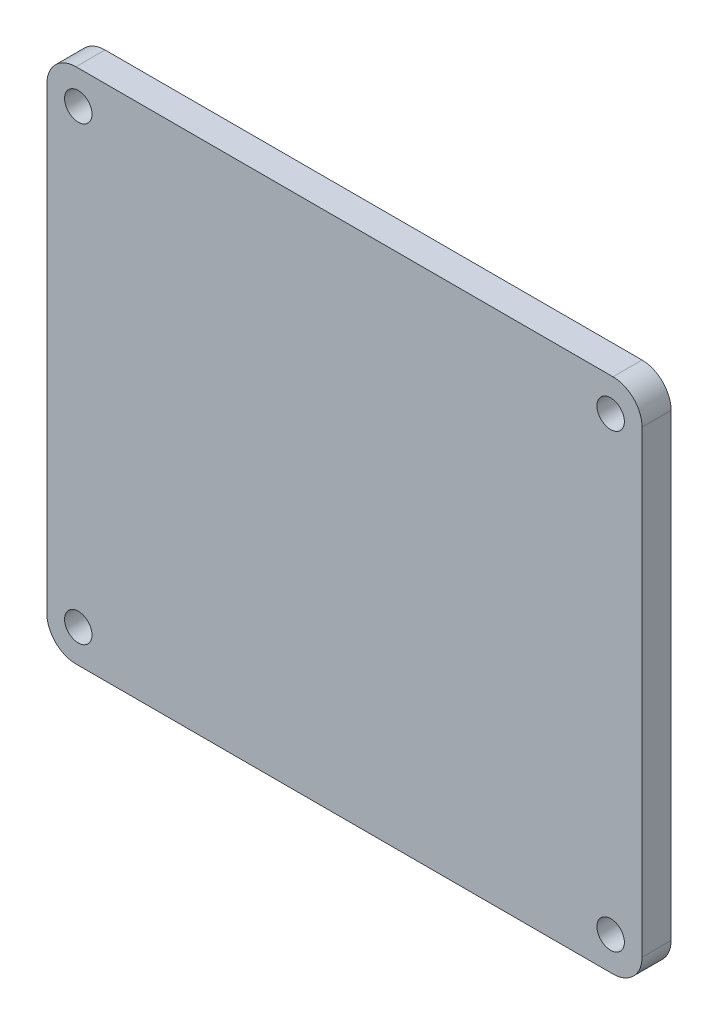
from build123d import *

# Parameters (mm, degrees)
SKETCH2_W                 = 65.024
SKETCH2_H                 = 56.515
BOSS_EXTRUDE1_DEPTH       = 3.175
F_3_0MM_DOWEL_HOLE1_D     = 3
F_3_0MM_DOWEL_HOLE1_DEPTH = 3.175
FILLET1_R                 = 3.175


with BuildPart() as part:
    # Sketch2 → Boss-Extrude1 (new body)
    with BuildSketch(Plane.XY.offset(50.8)):
        with Locations((0, 48.5775)):
            Rectangle(SKETCH2_W, SKETCH2_H)
    extrude(amount=-BOSS_EXTRUDE1_DEPTH)

    # Ø3.0mm Dowel Hole1
    with Locations(Plane.XY.offset(50.8)):
        with Locations((29.083, 73.2155), (29.083, 23.9395), (-29.083, 23.9395), (-29.083, 73.2155)):
            Hole(F_3_0MM_DOWEL_HOLE1_D / 2, depth=F_3_0MM_DOWEL_HOLE1_DEPTH)

    # Fillet1
    fillet1_edges = [part.edges().sort_by_distance(p)[0] for p in [
        (-32.512, 76.835, 49.2125),
        (32.512, 76.835, 49.2125),
        (32.512, 20.32, 49.2125),
        (-32.512, 20.32, 49.2125),
    ]]
    fillet(fillet1_edges, radius=FILLET1_R)


solid = part.part
